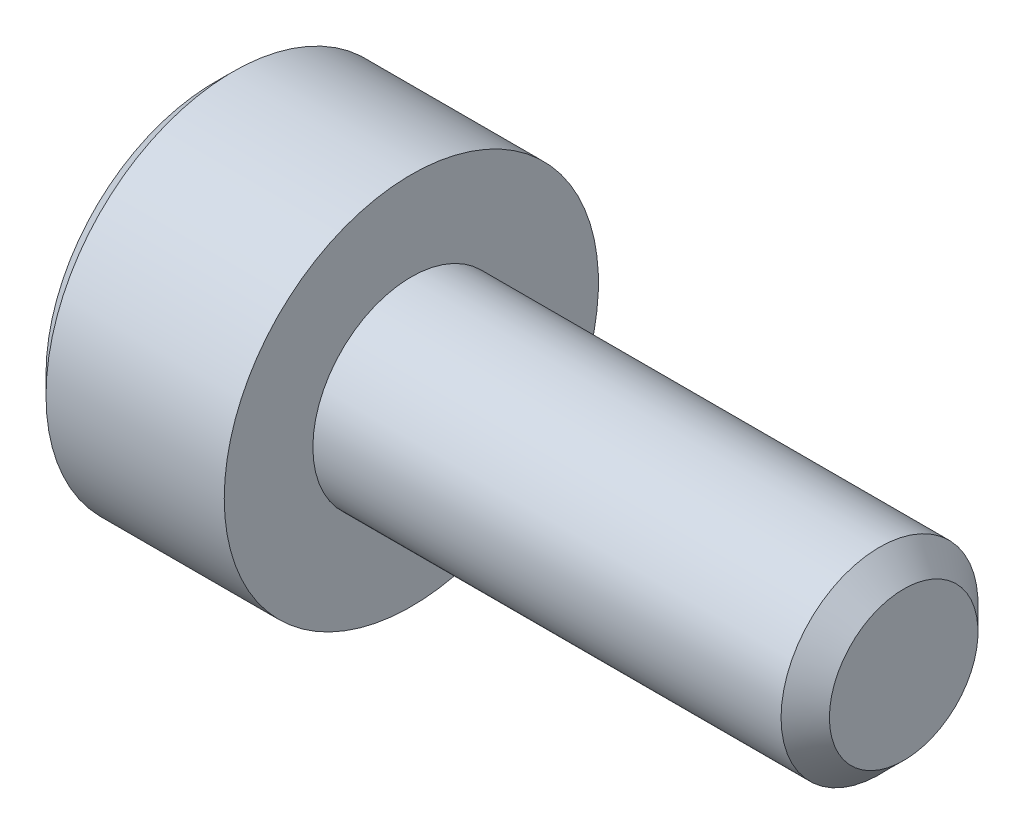
from build123d import *

# Parameters (mm, degrees)
CUT_EXTRUDE1_DEPTH = 0.8


with BuildPart() as part:
    # Sketch1 → Revolve1 (revolve)
    with BuildSketch(Plane.XY):
        Polygon((-2, 0), (-2, 1.71), (-1.81, 1.9), (0, 1.9), (0, 1), (4.7545, 1), (5, 0.7545), (5, 0), align=None)
    revolve(axis=Axis((5, 0, 0), (-1, 0, 0)))

    # Sketch2 → Cut-Extrude1 (cut)
    with BuildSketch(Plane(origin=(-2, 0, 0), x_dir=(0, 0, -1), z_dir=(1, 0, 0))):
        Polygon((-0.75, -0.433012702), (0, -0.866025404), (0.75, -0.433012702), (0.75, 0.433012702), (0, 0.866025404), (-0.75, 0.433012702), align=None)
    extrude(amount=CUT_EXTRUDE1_DEPTH, mode=Mode.SUBTRACT)


solid = part.part
